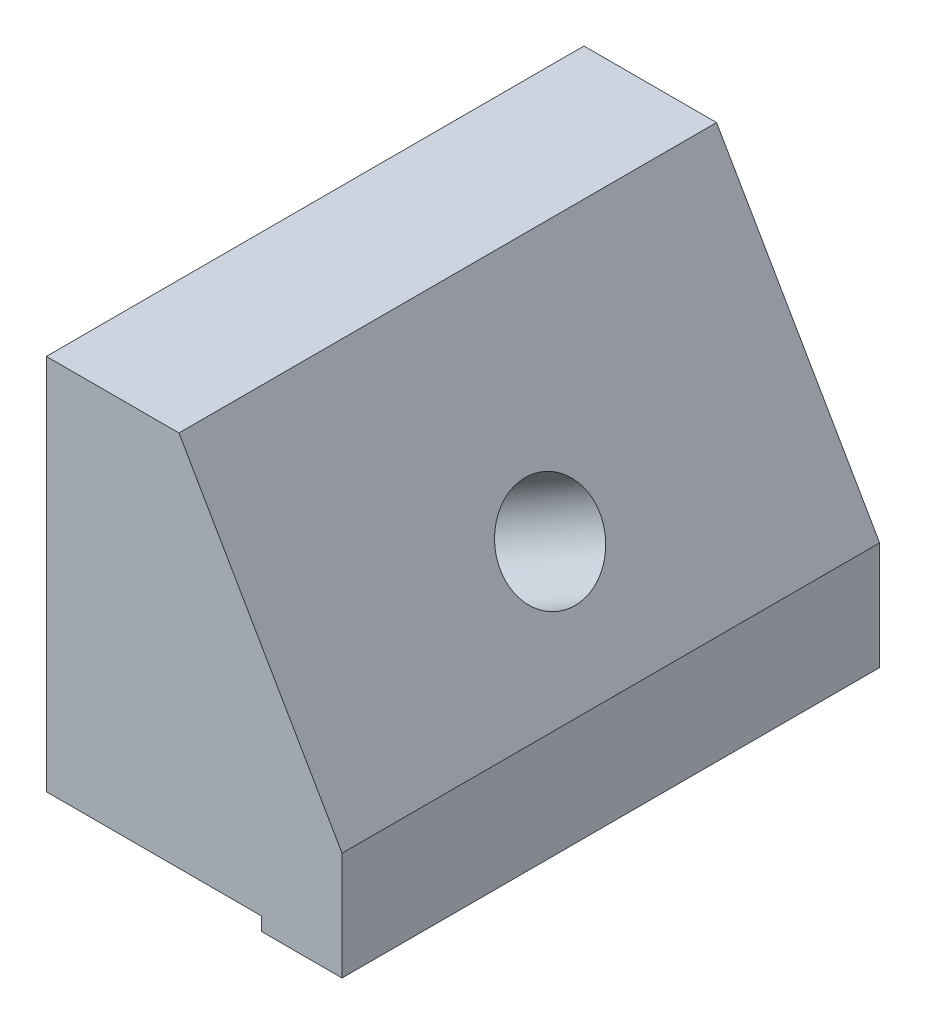
from build123d import *

# Parameters (mm, degrees)
EXTRUDE_1_DEPTH     = 20
SKETCH_2_R          = 1.85
CUT_EXTRUDE_1_DEPTH = 6
SKETCH_3_R          = 1.125
CUT_EXTRUDE_2_DEPTH = 20.825317547
SKETCH_4_OUTSIDE_W  = 36.206
SKETCH_4_OUTSIDE_H  = 39.867
CUT_EXTRUDE_3_DEPTH = 21
SKETCH_5_W          = 4
SKETCH_5_H          = 15
SKETCH_5_H_2        = 0.9
CUT_EXTRUDE_4_DEPTH = 21
SKETCH_6_W          = 4
SKETCH_6_H          = 7
CUT_EXTRUDE_5_DEPTH = 6.207259422
SKETCH_7_W          = 8
SKETCH_7_H          = 0.5
CUT_EXTRUDE_6_DEPTH = 21
CUT_EXTRUDE_7_DEPTH = 2


with BuildPart() as part:
    # Эскиз1 → Бобышка-Вытянуть1 (new body)
    with BuildSketch(Plane.XY):
        Polygon((-12.5, 21.650635095), (0, 0), (12.990381057, 7.5), (0.490381057, 29.150635095), align=None)
    extrude(amount=EXTRUDE_1_DEPTH)

    # Эскиз2 → Вырез-Вытянуть1 (cut)
    with BuildSketch(Plane(origin=(12.990381057, 7.5, 0), x_dir=(0, 0, -1), z_dir=(0.866025404, 0.5, 0))):
        with Locations((-10, 8)):
            Circle(SKETCH_2_R)
    extrude(amount=-CUT_EXTRUDE_1_DEPTH, mode=Mode.SUBTRACT)

    # Эскиз3 → Вырез-Вытянуть2 (cut, through all)
    with BuildSketch(Plane(origin=(7.794228634, 4.5, 0), x_dir=(0, 0, -1), z_dir=(0.866025404, 0.5, 0))):
        with Locations((-10, 8)):
            Circle(SKETCH_3_R)
    extrude(amount=-CUT_EXTRUDE_2_DEPTH, mode=Mode.SUBTRACT)

    # Эскиз4 outside → Вырез-Вытянуть3 (cut, through all)
    with BuildSketch(Plane.XY.offset(20)):
        with Locations((0.245, 14.5755)):
            Rectangle(SKETCH_4_OUTSIDE_W, SKETCH_4_OUTSIDE_H)
        Polygon((-3.75, 6.495190528), (11.25, 6.495190528), (11.25, 10.514428415), (1.903841409, 26.70244995), (-3.75, 26.70244995), align=None, mode=Mode.SUBTRACT)
    extrude(amount=-CUT_EXTRUDE_3_DEPTH, mode=Mode.SUBTRACT)

    # Эскиз5 → Вырез-Вытянуть4 (cut, through all)
    with BuildSketch(Plane.XY.offset(20)):
        with Locations((-1.75, 19.20244995)):
            Rectangle(SKETCH_5_W, SKETCH_5_H)
        with Locations((-1.75, 6.945190528)):
            Rectangle(SKETCH_5_W, SKETCH_5_H_2)
    extrude(amount=-CUT_EXTRUDE_4_DEPTH, mode=Mode.SUBTRACT)

    # Эскиз6 → Вырез-Вытянуть5 (cut, through all)
    with BuildSketch(Plane(origin=(0, 11.70244995, 0), x_dir=(1, 0, 0), z_dir=(0, 1, 0))):
        with Locations((-1.75, -16.5)):
            Rectangle(SKETCH_6_W, SKETCH_6_H)
        with Locations((-1.75, -3.5)):
            Rectangle(SKETCH_6_W, SKETCH_6_H)
    extrude(amount=-CUT_EXTRUDE_5_DEPTH, mode=Mode.SUBTRACT)

    # Эскиз7 → Вырез-Вытянуть6 (cut, through all)
    with BuildSketch(Plane.XY.offset(20)):
        Polygon((0.25, 21.022474586), (5.183176715, 21.022474586), (1.903841409, 26.70244995), (0.25, 26.70244995), align=None)
        with Locations((4.25, 6.745190528)):
            Rectangle(SKETCH_7_W, SKETCH_7_H)
    extrude(amount=-CUT_EXTRUDE_6_DEPTH, mode=Mode.SUBTRACT)

    # Эскиз8 → Вырез-Вытянуть7 (cut)
    with BuildSketch(Plane.XZ.offset(-6.995190528)):
        with BuildLine():
            Line((-3.75, 11.505998369), (0.25, 11.505998369))
            ThreePointArc((0.25, 11.505998369), (1.755998369, 10), (0.25, 8.494001631))
            Line((0.25, 8.494001631), (-3.75, 8.494001631))
            Line((-3.75, 8.494001631), (-3.75, 11.505998369))
        make_face()
    extrude(amount=-CUT_EXTRUDE_7_DEPTH, mode=Mode.SUBTRACT)


solid = part.part
